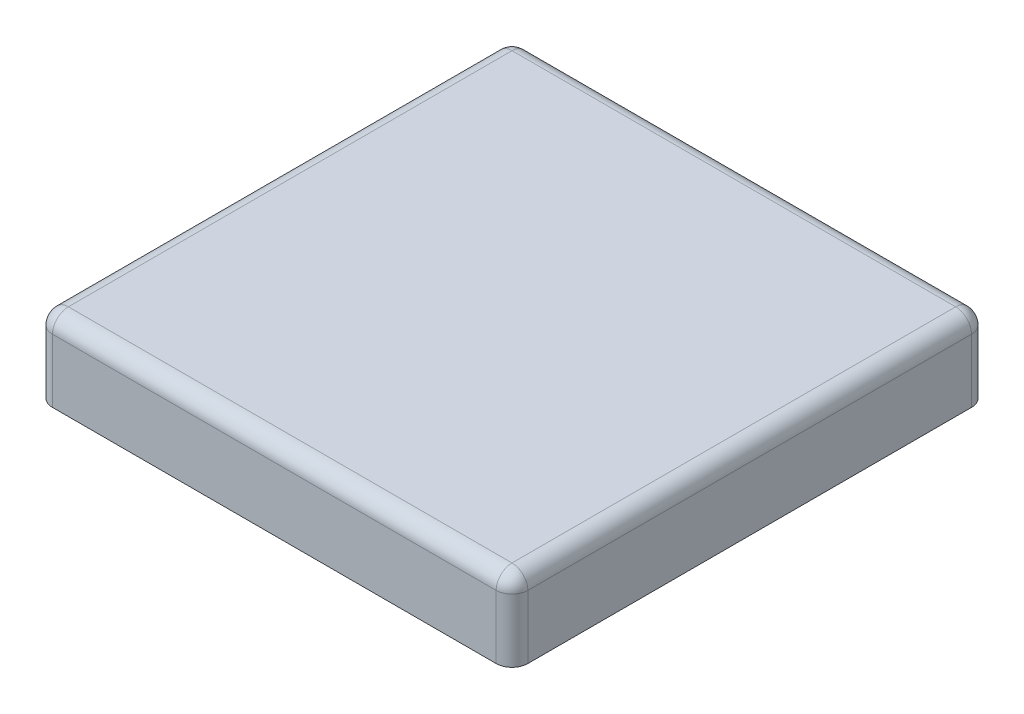
from build123d import *

# Parameters (mm, degrees)
SKETCH1_W           = 300
SKETCH1_H           = 300
BOSS_EXTRUDE1_DEPTH = 50
FILLET1_R           = 10


with BuildPart() as part:
    # Sketch1 → Boss-Extrude1 (new body)
    with BuildSketch(Plane(origin=(0, 0, 0), x_dir=(1, 0, 0), z_dir=(0, 1, 0))):
        Rectangle(SKETCH1_W, SKETCH1_H)
    extrude(amount=BOSS_EXTRUDE1_DEPTH)

    # Fillet1
    fillet1_edges = [part.edges().sort_by_distance(p)[0] for p in [
        (150, 50, 0),
        (0, 50, -150),
        (-150, 50, 0),
        (-150, 25, -150),
        (150, 25, -150),
        (150, 25, 150),
        (-150, 25, 150),
        (0, 50, 150),
    ]]
    fillet(fillet1_edges, radius=FILLET1_R)


solid = part.part
